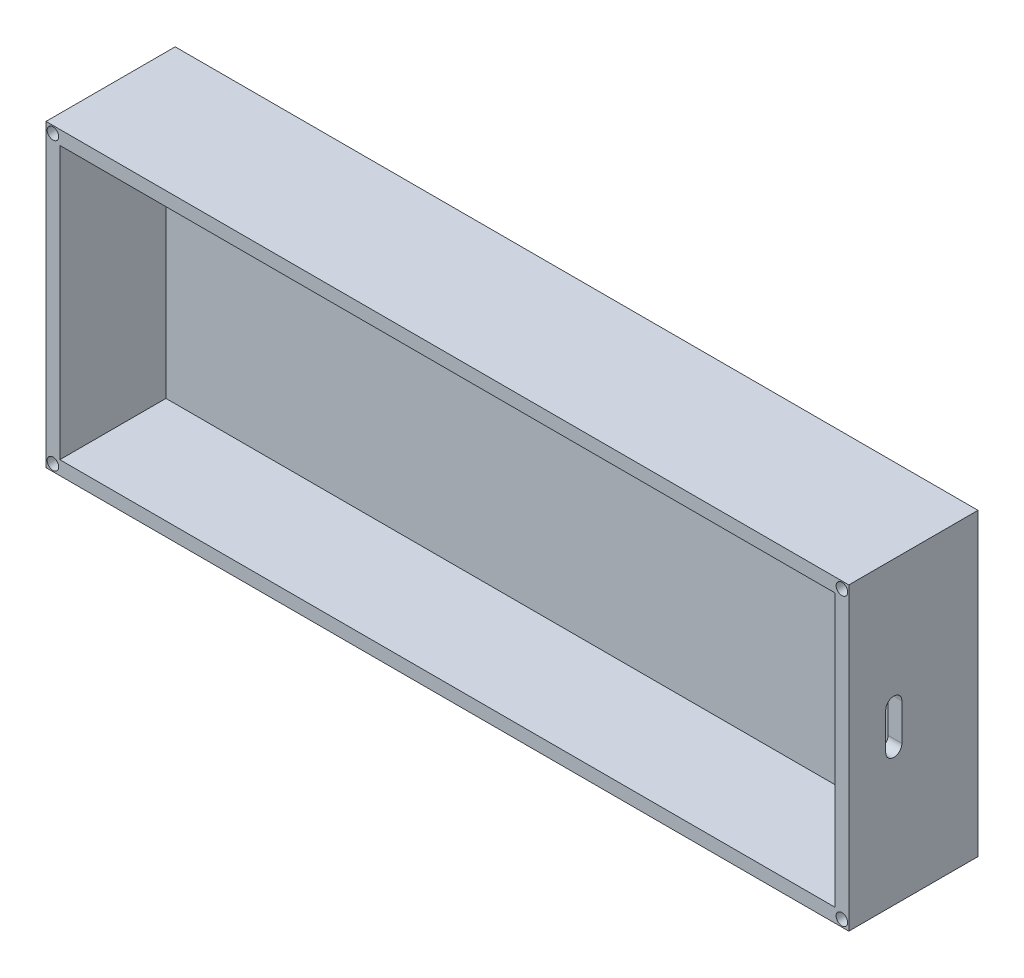
from build123d import *

# Parameters (mm, degrees)
SKETCH1_W           = 174
SKETCH1_H           = 65
BOSS_EXTRUDE1_DEPTH = 5
SKETCH3_W           = 174
SKETCH3_H           = 65
SKETCH3_W_2         = 168
SKETCH3_H_2         = 59
BOSS_EXTRUDE3_DEPTH = 23
CUT_EXTRUDE1_DEPTH  = 23
SKETCH17_R          = 1.25
CUT_EXTRUDE5_DEPTH  = 4
SKETCH15_R          = 1.25
CUT_EXTRUDE4_DEPTH  = 4
SKETCH11_R          = 1.25
SKETCH11_R_2        = 0.084381571
CUT_EXTRUDE2_DEPTH  = 4
SKETCH13_R          = 0.084381571
CUT_EXTRUDE3_DEPTH  = 4


with BuildPart() as part:
    # Sketch1 → Boss-Extrude1 (new body)
    with BuildSketch(Plane.XY):
        Rectangle(SKETCH1_W, SKETCH1_H)
    extrude(amount=BOSS_EXTRUDE1_DEPTH)

    # Sketch3 → Boss-Extrude3 (add)
    with BuildSketch(Plane.XY.offset(5)):
        Rectangle(SKETCH3_W, SKETCH3_H)
        Rectangle(SKETCH3_W_2, SKETCH3_H_2, mode=Mode.SUBTRACT)
    extrude(amount=BOSS_EXTRUDE3_DEPTH)

    # Sketch9 → Cut-Extrude1 (cut)
    with BuildSketch(Plane(origin=(87, 0, 0), x_dir=(0, 0, -1), z_dir=(1, 0, 0))):
        with BuildLine():
            Line((-20, -3), (-20, 5))
            ThreePointArc((-20, 5), (-18.25, 6.75), (-16.5, 5))
            Line((-16.5, 5), (-16.5, -3))
            ThreePointArc((-16.5, -3), (-18.25, -4.75), (-20, -3))
        make_face()
    extrude(amount=-CUT_EXTRUDE1_DEPTH, mode=Mode.SUBTRACT)

    # Sketch17 → Cut-Extrude5 (cut)
    with BuildSketch(Plane.XY.offset(28)):
        with Locations((-85.5, -31)):
            Circle(SKETCH17_R)
        with Locations((-85.5, 31)):
            Circle(SKETCH17_R)
        with Locations((85.5, 31)):
            Circle(SKETCH17_R)
        with Locations((85.5, -31)):
            Circle(SKETCH17_R)
    extrude(amount=-CUT_EXTRUDE5_DEPTH, mode=Mode.SUBTRACT)

    # Sketch15 → Cut-Extrude4 (cut)
    with BuildSketch(Plane.XY.offset(28)):
        with Locations((-85.5, 31)):
            Circle(SKETCH15_R)
    extrude(amount=-CUT_EXTRUDE4_DEPTH, mode=Mode.SUBTRACT)

    # Sketch11 → Cut-Extrude2 (cut)
    with BuildSketch(Plane.XY.offset(28)):
        with Locations((-85.5, 31)):
            Circle(SKETCH11_R)
        with Locations((-85.5, 31)):
            Circle(SKETCH11_R_2, mode=Mode.SUBTRACT)
    extrude(amount=-CUT_EXTRUDE2_DEPTH, mode=Mode.SUBTRACT)

    # Sketch13 → Cut-Extrude3 (cut)
    with BuildSketch(Plane.XY.offset(28)):
        with Locations((-85.5, 31)):
            Circle(SKETCH13_R)
    extrude(amount=-CUT_EXTRUDE3_DEPTH, mode=Mode.SUBTRACT)


solid = part.part
